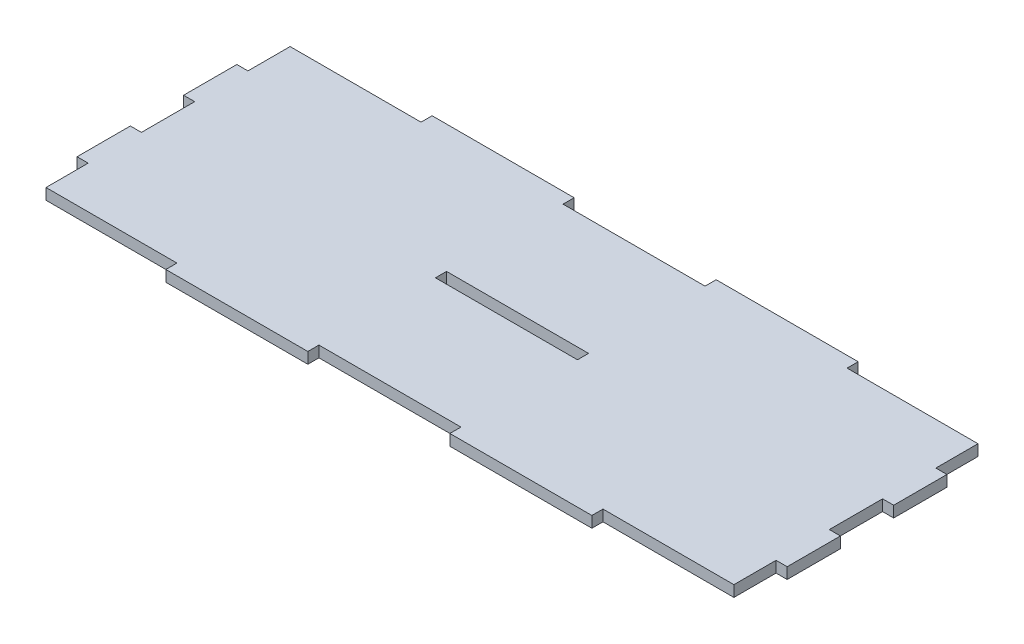
from build123d import *

# Parameters (mm, degrees)
SKETCH1_W           = 203.2
SKETCH1_H           = 76.2
BOSS_EXTRUDE1_DEPTH = 3.175
SKETCH2_W           = 40.64
SKETCH2_H           = 3.175
CUT_EXTRUDE1_DEPTH  = 3.175
LPATTERN1_COUNT     = 3
LPATTERN1_PITCH     = 81.28
SKETCH3_W           = 3.175
SKETCH3_H           = 15.24
CUT_EXTRUDE2_DEPTH  = 3.175
LPATTERN2_COUNT     = 3
LPATTERN2_PITCH     = 30.48
SKETCH4_W           = 40.64
SKETCH4_H           = 3.175
CUT_EXTRUDE3_DEPTH  = 3.175


with BuildPart() as part:
    # Sketch1 → Boss-Extrude1 (new body)
    with BuildSketch(Plane(origin=(0, 0, 0), x_dir=(1, 0, 0), z_dir=(0, 1, 0))):
        Rectangle(SKETCH1_W, SKETCH1_H)
    extrude(amount=BOSS_EXTRUDE1_DEPTH)

    # Sketch2 → Cut-Extrude1 (cut)
    with BuildSketch(Plane(origin=(0, 3.175, 0), x_dir=(1, 0, 0), z_dir=(0, 1, 0))):
        with Locations((-81.28, 36.5125)):
            Rectangle(SKETCH2_W, SKETCH2_H)
        with Locations((-81.28, -36.5125)):
            Rectangle(SKETCH2_W, SKETCH2_H)
    cut_extrude1 = extrude(amount=-CUT_EXTRUDE1_DEPTH, mode=Mode.SUBTRACT)

    # LPattern1: Cut-Extrude1 ×3
    with Locations(*[(i * LPATTERN1_PITCH, 0, 0) for i in range(1, LPATTERN1_COUNT)]):
        add(cut_extrude1, mode=Mode.SUBTRACT)

    # Sketch3 → Cut-Extrude2 (cut)
    with BuildSketch(Plane(origin=(0, 3.175, 0), x_dir=(1, 0, 0), z_dir=(0, 1, 0))):
        with Locations((100.0125, 30.48)):
            Rectangle(SKETCH3_W, SKETCH3_H)
        with Locations((-100.0125, 30.48)):
            Rectangle(SKETCH3_W, SKETCH3_H)
    cut_extrude2 = extrude(amount=-CUT_EXTRUDE2_DEPTH, mode=Mode.SUBTRACT)

    # LPattern2: Cut-Extrude2 ×3
    with Locations(*[(0, 0, i * LPATTERN2_PITCH) for i in range(1, LPATTERN2_COUNT)]):
        add(cut_extrude2, mode=Mode.SUBTRACT)

    # Sketch4 → Cut-Extrude3 (cut)
    with BuildSketch(Plane(origin=(0, 3.175, 0), x_dir=(1, 0, 0), z_dir=(0, 1, 0))):
        Rectangle(SKETCH4_W, SKETCH4_H)
    extrude(amount=-CUT_EXTRUDE3_DEPTH, mode=Mode.SUBTRACT)


solid = part.part
